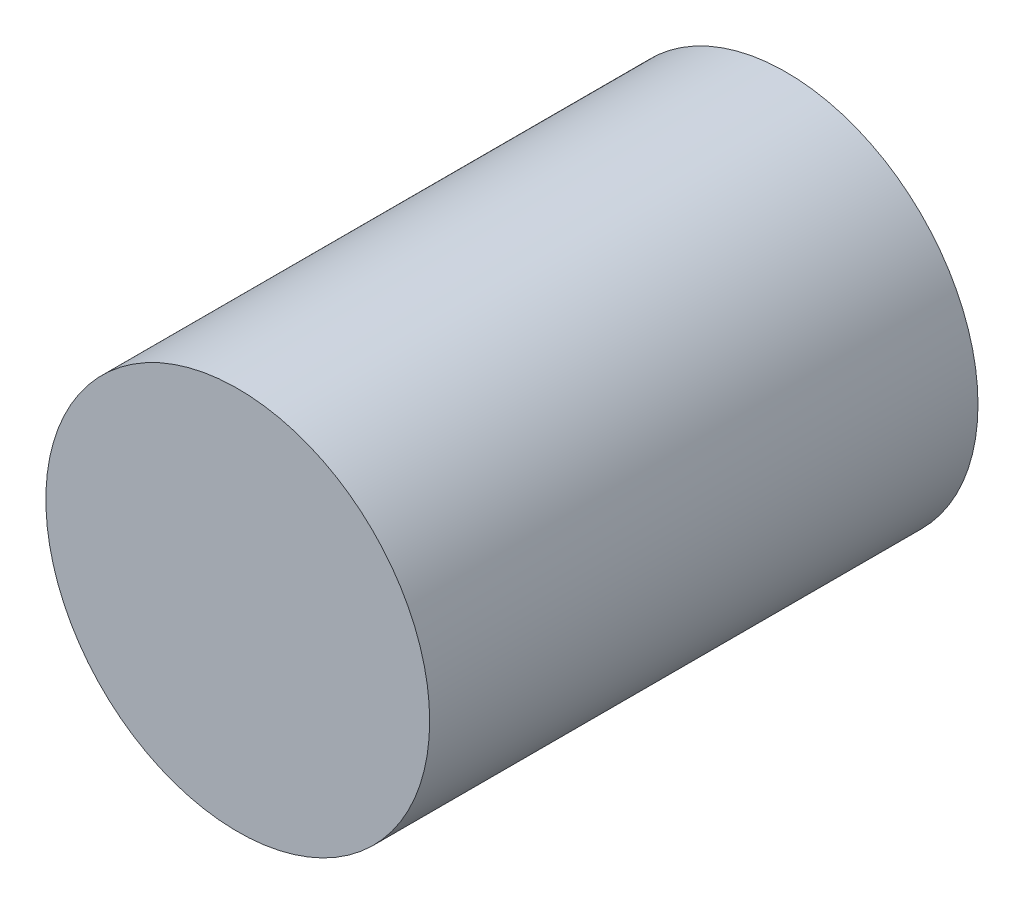
from build123d import *

# Parameters (mm, degrees)
IZIM1_R                     = 4.445
Y_KSEKLIK_EKSTR_ZYON1_DEPTH = 12.7


with BuildPart() as part:
    # Çizim1 → Yükseklik-Ekstrüzyon1 (new body)
    with BuildSketch(Plane.XY):
        Circle(IZIM1_R)
    extrude(amount=Y_KSEKLIK_EKSTR_ZYON1_DEPTH)


solid = part.part
